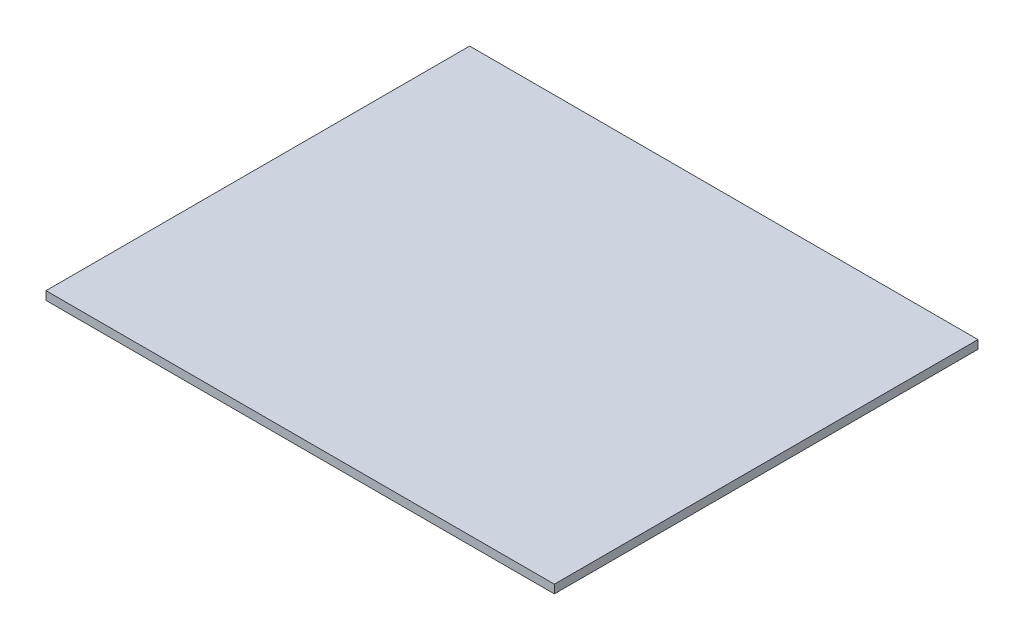
from build123d import *

# Parameters (mm, degrees)
SKETCH1_W           = 152.4
SKETCH1_H           = 127
BOSS_EXTRUDE1_DEPTH = 2.54


with BuildPart() as part:
    # Sketch1 → Boss-Extrude1 (new body)
    with BuildSketch(Plane(origin=(0, 0, 0), x_dir=(1, 0, 0), z_dir=(0, 1, 0))):
        Rectangle(SKETCH1_W, SKETCH1_H)
    extrude(amount=BOSS_EXTRUDE1_DEPTH)


solid = part.part
